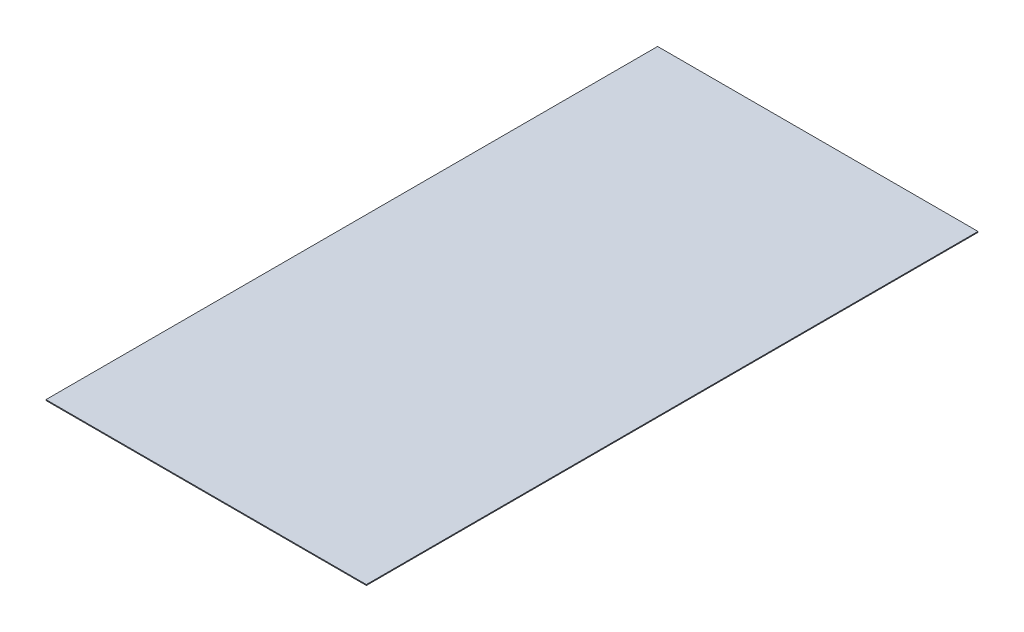
from build123d import *

# Parameters (mm, degrees)
SKETCH1_W           = 1100
SKETCH1_H           = 2100
BOSS_EXTRUDE1_DEPTH = 3


with BuildPart() as part:
    # Sketch1 → Boss-Extrude1 (new body)
    with BuildSketch(Plane(origin=(0, 0, 0), x_dir=(1, 0, 0), z_dir=(0, 1, 0))):
        Rectangle(SKETCH1_W, SKETCH1_H)
    extrude(amount=BOSS_EXTRUDE1_DEPTH)


solid = part.part
